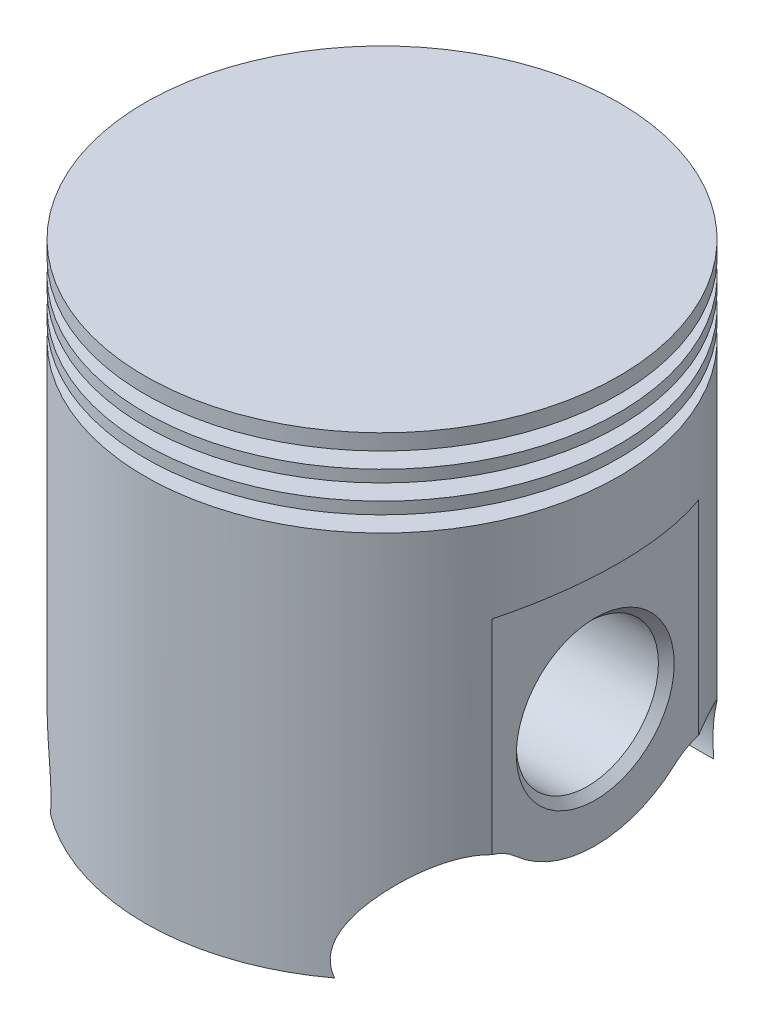
from build123d import *

# Parameters (mm, degrees)
SKETCH2_R           = 12.5
BOSS_EXTRUDE1_DEPTH = 17.27178
SKETCH3_R           = 9
CUT_EXTRUDE1_DEPTH  = 56.5
SKETCH4_W           = 35
SKETCH4_H           = 35
CUT_EXTRUDE3_DEPTH  = 3
CUT_EXTRUDE3_TAPER  = 20
CHAMFER1_SIZE       = 1
CUT_EXTRUDE4_DEPTH  = 56


with BuildPart() as part:
    # Sketch1 → Revolve1 (revolve)
    with BuildSketch(Plane(origin=(0, 0, 0), x_dir=(0, 0, -1), z_dir=(1, 0, 0))):
        Polygon((0, 0), (30, 0), (30, -2), (25.52, -2), (25.52, -4), (30, -4), (30, -5.5), (25.52, -5.5), (25.52, -7.5), (30, -7.5), (30, -9), (25.52, -9), (25.52, -11), (30, -11), (30, -60), (26, -60), (26, -54), (22.020616019, -50.660900369), (22.020616019, -40.660900369), (24, -39), (24, -7.5), (0, -7.5), align=None)
    revolve(axis=Axis((0, -7.5, 0), (0, 1, 0)))

    # Sketch2 → Boss-Extrude1 (add)
    with BuildSketch(Plane(origin=(10, 0, 0), x_dir=(0, 0, -1), z_dir=(1, 0, 0))):
        with Locations((0, -38)):
            Circle(SKETCH2_R)
    boss_extrude1 = extrude(amount=BOSS_EXTRUDE1_DEPTH)

    # Mirror1: Boss-Extrude1 across plane
    add(boss_extrude1.mirror(Plane(origin=(0, 0, 0), x_dir=(0, 0, 1), z_dir=(1, 0, 0))))

    # Sketch3 → Cut-Extrude1 (cut, symmetric)
    with BuildSketch(Plane(origin=(0, 0, 0), x_dir=(0, 0, -1), z_dir=(1, 0, 0))):
        with Locations((0, -38)):
            Circle(SKETCH3_R)
    extrude(amount=CUT_EXTRUDE1_DEPTH, both=True, mode=Mode.SUBTRACT)

    # Sketch4 → Cut-Extrude3 (cut)
    with BuildSketch(Plane(origin=(30, 0, 0), x_dir=(0, 0, -1), z_dir=(1, 0, 0))):
        with Locations((0, -38)):
            Rectangle(SKETCH4_W, SKETCH4_H)
    cut_extrude3 = extrude(amount=-CUT_EXTRUDE3_DEPTH, taper=CUT_EXTRUDE3_TAPER, mode=Mode.SUBTRACT)

    # Mirror2: Cut-Extrude3 across plane
    add(cut_extrude3.mirror(Plane(origin=(0, 0, 0), x_dir=(0, 0, 1), z_dir=(1, 0, 0))), mode=Mode.SUBTRACT)

    # Chamfer1
    chamfer1_edges = [part.edges().sort_by_distance(p)[0] for p in [
        (-27, -38, 9),
        (27, -38, 9),
    ]]
    chamfer(chamfer1_edges, length=CHAMFER1_SIZE)

    # Sketch5 → Cut-Extrude4 (cut, symmetric)
    with BuildSketch(Plane(origin=(0, 0, 0), x_dir=(0, 0, -1), z_dir=(1, 0, 0))):
        with BuildLine():
            Line((-24, -60), (24, -60))
            add(Edge.make_bspline(
                [(10, -49.180339887), (16.990690215, -42.927676475), (25.809268179, -52.921487924), (24, -60)],
                knots=[0, 0, 0, 0, 1, 1, 1, 1], degree=3))
            ThreePointArc((10, -49.180339887), (0, -53), (-10, -49.180339887))
            add(Edge.make_bspline(
                [(-10, -49.180339887), (-16.990690215, -42.927676475), (-25.809268179, -52.921487924), (-24, -60)],
                knots=[0, 0, 0, 0, 1, 1, 1, 1], degree=3))
        make_face()
    extrude(amount=CUT_EXTRUDE4_DEPTH, both=True, mode=Mode.SUBTRACT)


solid = part.part
